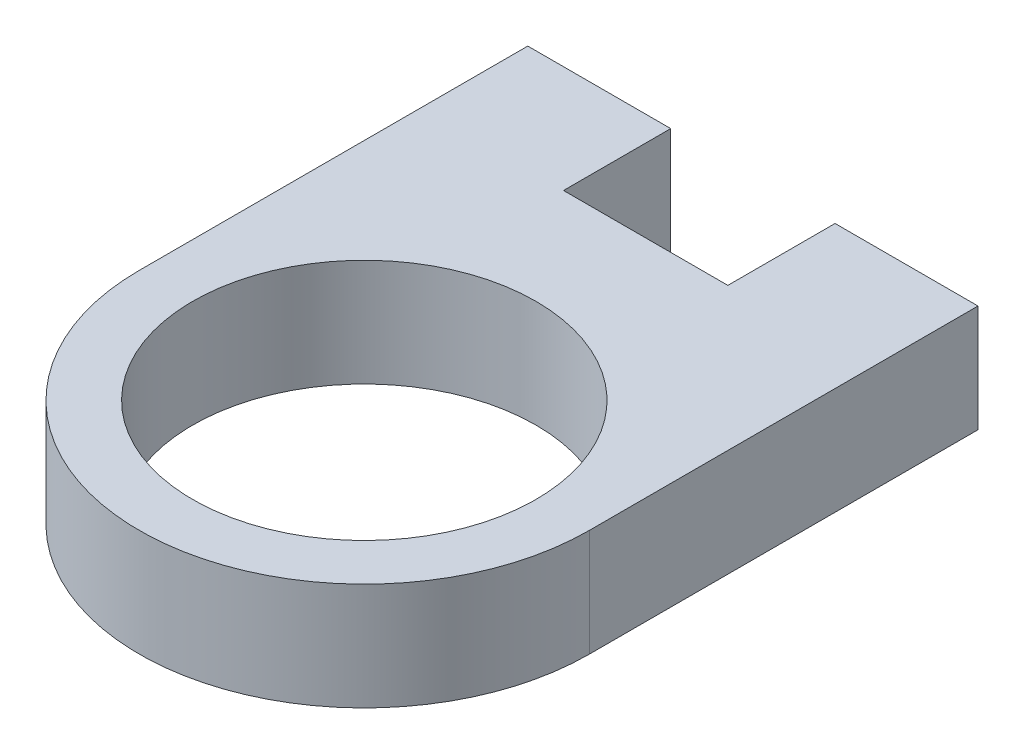
from build123d import *

# Parameters (mm, degrees)
BOSS_EXTRUDE1_DEPTH = 7.62
SKETCH2_R           = 12.2
CUT_EXTRUDE1_DEPTH  = 8.62
SKETCH3_W           = 10.16
SKETCH3_H           = 7.62
BOSS_EXTRUDE2_DEPTH = 7.62


with BuildPart() as part:
    # Sketch1 → Boss-Extrude1 (new body)
    with BuildSketch(Plane(origin=(0, 0, 0), x_dir=(1, 0, 0), z_dir=(0, 1, 0))):
        with BuildLine():
            Line((0, 0), (0, 20))
            Line((0, 20), (32, 20))
            Line((32, 20), (32, 0))
            ThreePointArc((32, 0), (16, -16), (0, 0))
        make_face()
    extrude(amount=BOSS_EXTRUDE1_DEPTH)

    # Sketch2 → Cut-Extrude1 (cut, through all)
    with BuildSketch(Plane.XZ):
        with Locations((16, 0)):
            Circle(SKETCH2_R)
    extrude(amount=-CUT_EXTRUDE1_DEPTH, mode=Mode.SUBTRACT)

    # Sketch3 → Boss-Extrude2 (add)
    with BuildSketch(Plane(origin=(0, 0, -20), x_dir=(-1, 0, 0), z_dir=(0, 0, -1))):
        with Locations((-26.92, 3.81)):
            Rectangle(SKETCH3_W, SKETCH3_H)
        with Locations((-5.08, 3.81)):
            Rectangle(SKETCH3_W, SKETCH3_H)
    extrude(amount=BOSS_EXTRUDE2_DEPTH)


solid = part.part
